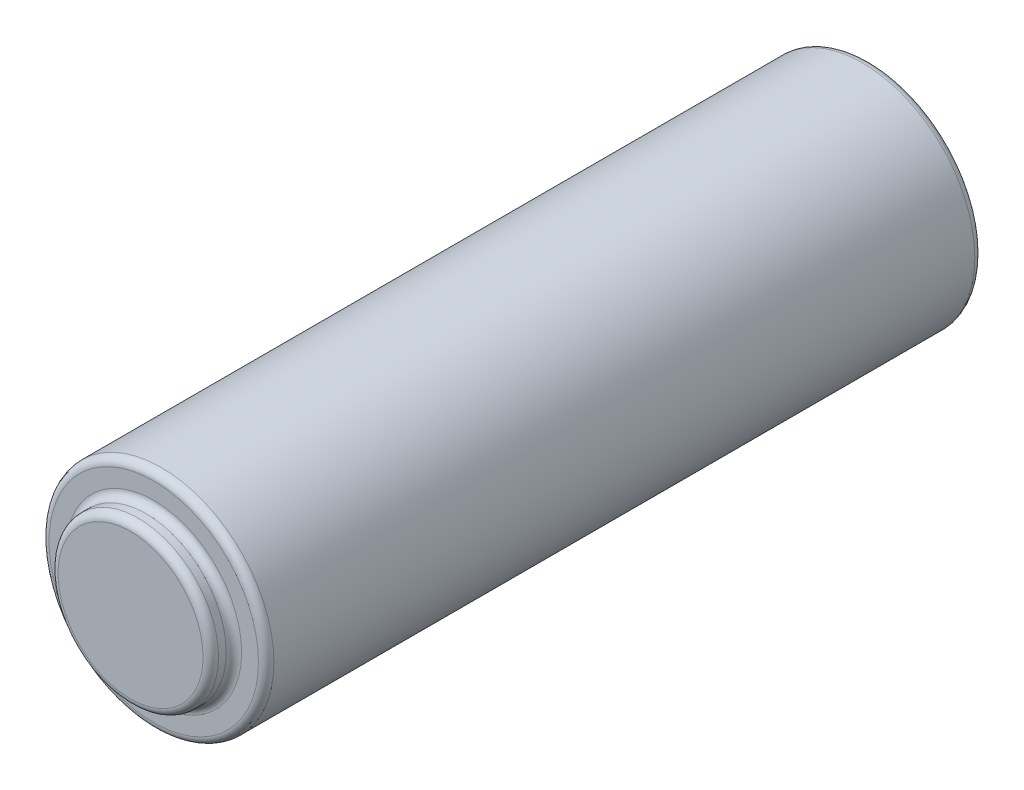
from build123d import *

# Parameters (mm, degrees)
SKETCH1_R           = 7.400445615
BOSS_EXTRUDE1_DEPTH = 47.157501005
SKETCH2_R           = 5.279749884
BOSS_EXTRUDE2_DEPTH = 1.524
FILLET1_R           = 0.508
FILLET2_R           = 0.508
FILLET3_R           = 0.508


with BuildPart() as part:
    # Sketch1 → Boss-Extrude1 (new body)
    with BuildSketch(Plane.XY):
        with Locations((23.495, 8.89)):
            Circle(SKETCH1_R)
    extrude(amount=BOSS_EXTRUDE1_DEPTH)

    # Sketch2 → Boss-Extrude2 (add)
    with BuildSketch(Plane.XY.offset(47.157501005)):
        with Locations((23.495, 8.89)):
            Circle(SKETCH2_R)
    extrude(amount=BOSS_EXTRUDE2_DEPTH)

    # Fillet1
    fillet1_edges = [part.edges().sort_by_distance(p)[0] for p in [
        (18.215250116, 8.89, 48.681501005),
    ]]
    fillet(fillet1_edges, radius=FILLET1_R)

    # Fillet2
    fillet2_edges = [part.edges().sort_by_distance(p)[0] for p in [
        (16.094554385, 8.89, 47.157501005),
        (18.215250116, 8.89, 47.157501005),
    ]]
    fillet(fillet2_edges, radius=FILLET2_R)

    # Fillet3
    fillet3_edges = [part.edges().sort_by_distance(p)[0] for p in [
        (16.094554385, 8.89, 0),
    ]]
    fillet(fillet3_edges, radius=FILLET3_R)


solid = part.part
